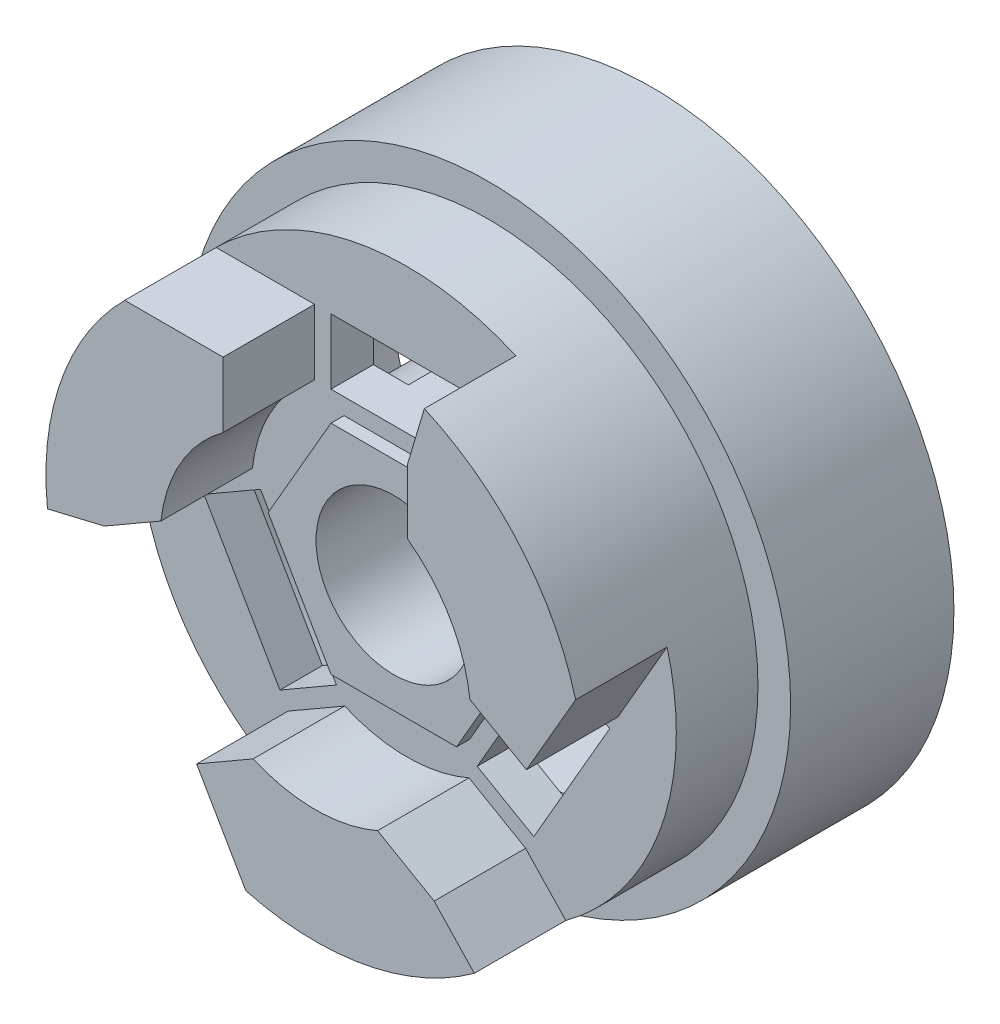
from build123d import *

# Parameters (mm, degrees)
SKETCH1_R                = 9.25
SKETCH1_R_2              = 7.95
BOSS_EXTRUDE1_DEPTH      = 5
BOSS_EXTRUDE2_START      = 5
SKETCH3_R                = 8.25
SKETCH3_R_2              = 6.95
BOSS_EXTRUDE2_DEPTH      = 2.5
BOSS_EXTRUDE2_DEPTH_BACK = 1
SKETCH4_R                = 8.25
BOSS_EXTRUDE3_DEPTH      = 1.3
SKETCH5_R                = 4.03
SKETCH5_R_2              = 2.38
BOSS_EXTRUDE4_DEPTH      = 6.7
SKETCH5_2_R              = 2.38
CUT_EXTRUDE1_DEPTH       = 15.697448758
SKETCH6_W                = 4.65
SKETCH6_H                = 2
CUT_EXTRUDE2_DEPTH       = 16.333786225
CIRPATTERN1_COUNT        = 3
SKETCH7_R                = 2.38
BOSS_EXTRUDE5_DEPTH      = 0.4
BOSS_EXTRUDE6_DEPTH      = 2.8
CIRPATTERN2_COUNT        = 3


with BuildPart() as part:
    # Sketch1 → Boss-Extrude1 (new body)
    with BuildSketch(Plane.XY):
        Circle(SKETCH1_R)
        Circle(SKETCH1_R_2, mode=Mode.SUBTRACT)
    extrude(amount=BOSS_EXTRUDE1_DEPTH)

    # Sketch3 → Boss-Extrude2 (add, two sides)
    with BuildSketch(Plane.XY.offset(BOSS_EXTRUDE2_START)) as boss_extrude2_sk:
        Circle(SKETCH3_R)
        Circle(SKETCH3_R_2, mode=Mode.SUBTRACT)
    extrude(amount=BOSS_EXTRUDE2_DEPTH)
    extrude(boss_extrude2_sk.sketch, amount=-BOSS_EXTRUDE2_DEPTH_BACK)

    # Sketch4 → Boss-Extrude3 (add)
    with BuildSketch(Plane.XY.offset(7.5)):
        Circle(SKETCH4_R)
    extrude(amount=-BOSS_EXTRUDE3_DEPTH)

    # Sketch5 → Boss-Extrude4 (add)
    with BuildSketch(Plane(origin=(0, 0, 6.2), x_dir=(-1, 0, 0), z_dir=(0, 0, -1))):
        with Locations(Location((0, 0, 0), (0, 0, 180))):
            Circle(SKETCH5_R)
        with Locations(Location((0, 0, 0), (0, 0, 180))):
            Circle(SKETCH5_R_2, mode=Mode.SUBTRACT)
    extrude(amount=BOSS_EXTRUDE4_DEPTH)

    # Sketch5_2 → Cut-Extrude1 (cut, through all)
    with BuildSketch(Plane(origin=(0, 0, 6.2), x_dir=(-1, 0, 0), z_dir=(0, 0, -1))):
        with Locations(Location((0, 0, 0), (0, 0, 180))):
            Circle(SKETCH5_2_R)
    extrude(amount=-CUT_EXTRUDE1_DEPTH, mode=Mode.SUBTRACT)

    # Sketch6 → Cut-Extrude2 (cut, through all)
    with BuildSketch(Plane.XY.offset(7.5)):
        with Locations((0, 4.83)):
            Rectangle(SKETCH6_W, SKETCH6_H)
    cut_extrude2 = extrude(amount=-CUT_EXTRUDE2_DEPTH, mode=Mode.SUBTRACT)

    # CirPattern1: Cut-Extrude2 ×3 about axis
    cirpattern1_axis = Axis((0, 0, 0), (0, 0, 1))
    for i in range(1, CIRPATTERN1_COUNT):
        add(cut_extrude2.rotate(cirpattern1_axis, i * 360 / CIRPATTERN1_COUNT), mode=Mode.SUBTRACT)

    # Sketch7 → Boss-Extrude5 (add)
    with BuildSketch(Plane.XY.offset(7.5)):
        Polygon((-1.922576396, -3.33), (1.922576396, -3.33), (3.845152793, 0), (1.922576396, 3.33), (-1.922576396, 3.33), (-3.845152793, 0), align=None)
        Circle(SKETCH7_R, mode=Mode.SUBTRACT)
    extrude(amount=BOSS_EXTRUDE5_DEPTH)

    # Sketch8 → Boss-Extrude6 (add)
    with BuildSketch(Plane.XY.offset(7.5)):
        with BuildLine():
            Line((3.636428104, -5.361521766), (1.904377296, -4.361521766))
            ThreePointArc((1.904377296, -4.361521766), (0, -4.75915171), (-1.904377296, -4.361521766))
            Line((-1.904377296, -4.361521766), (-3.636428104, -5.361521766))
            Line((-3.636428104, -5.361521766), (-2.130298289, -7.970215129))
            ThreePointArc((-2.130298289, -7.970215129), (1.516159822, -8.109485766), (4.865989618, -6.662180201))
            Line((4.865989618, -6.662180201), (3.636428104, -5.361521766))
        make_face()
    boss_extrude6 = extrude(amount=BOSS_EXTRUDE6_DEPTH)

    # CirPattern2: Boss-Extrude6 ×3 about axis
    cirpattern2_axis = Axis((0, 0, 0), (0, 0, 1))
    for i in range(1, CIRPATTERN2_COUNT):
        add(boss_extrude6.rotate(cirpattern2_axis, i * 360 / CIRPATTERN2_COUNT))


solid = part.part
